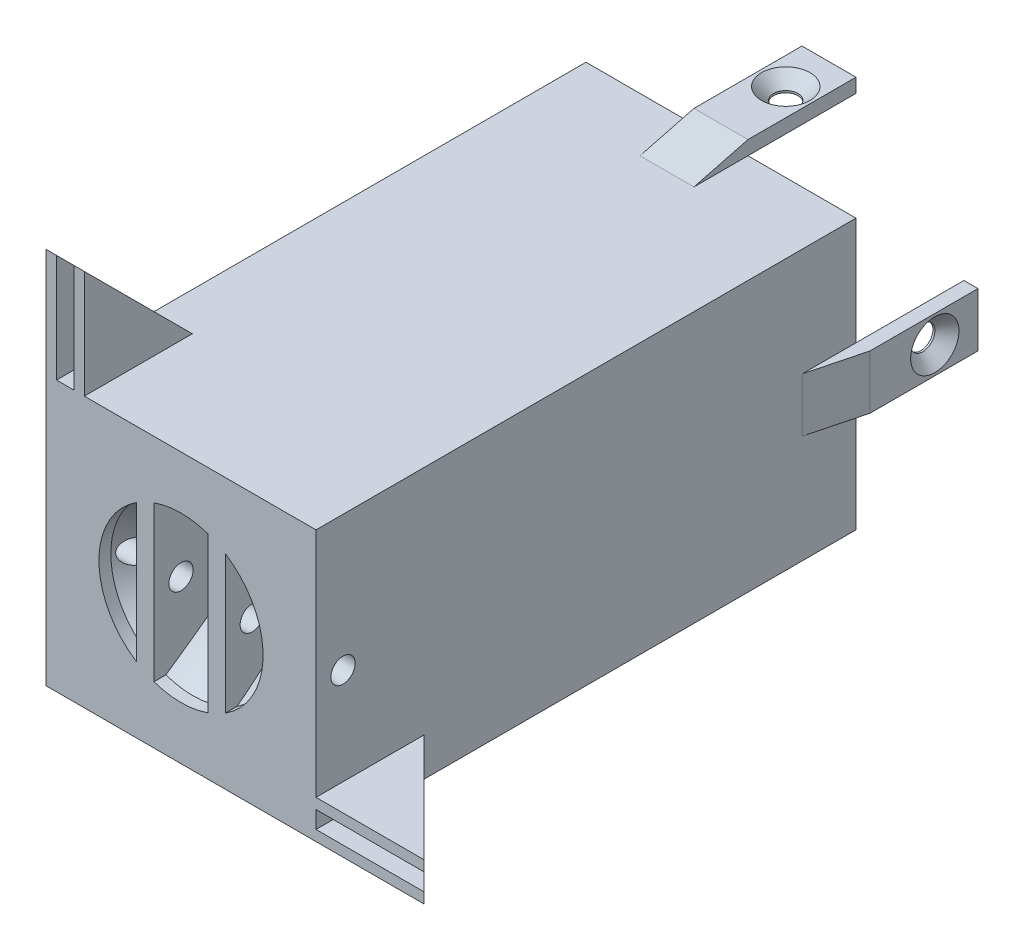
from build123d import *

# Parameters (mm, degrees)
CROQUIS1_W                                           = 50
CROQUIS1_H                                           = 50
CROQUIS1_R                                           = 2
SALIENTE_EXTRUIR2_DEPTH                              = 100
CROQUIS4_W                                           = 3.2
CROQUIS4_H                                           = 40
SALIENTE_EXTRUIR5_DEPTH                              = 10.2
CROQUIS8_R                                           = 4
CORTAR_EXTRUIR3_DEPTH                                = 87.4
CORTAR_EXTRUIR2_START                                = -50
CROQUIS7_R                                           = 2
CORTAR_EXTRUIR2_DEPTH                                = 50
REFRENTADO_PARA_TORNILLO_TAP_N_CON_CABEZ_D           = 4.5
REFRENTADO_PARA_TORNILLO_TAP_N_CON_CABEZ_CSINK_D     = 8.96
REFRENTADO_PARA_TORNILLO_TAP_N_CON_CABEZ_CSINK_ANGLE = 90
SALIENTE_EXTRUIR6_DEPTH                              = 1.95
SALIENTE_EXTRUIR7_START                              = -5.15
SALIENTE_EXTRUIR7_DEPTH                              = 1.95
SALIENTE_EXTRUIR9_DEPTH                              = 1.95
SALIENTE_EXTRUIR10_START                             = -5.15
SALIENTE_EXTRUIR10_DEPTH                             = 1.95
SALIENTE_EXTRUIR11_START                             = -25
SALIENTE_EXTRUIR11_DEPTH                             = 5
CROQUIS17_R                                          = 2.25
CORTAR_EXTRUIR4_DEPTH                                = 2.6
REFRENTADO_PARA_TORNILLO_TAP_N_CON_C_2_D             = 4.5
REFRENTADO_PARA_TORNILLO_TAP_N_CON_C_2_CSINK_D       = 8.96
REFRENTADO_PARA_TORNILLO_TAP_N_CON_C_2_CSINK_ANGLE   = 90


with BuildPart() as part:
    # Croquis1 → Saliente-Extruir2 (new body)
    with BuildSketch(Plane.XY):
        Rectangle(CROQUIS1_W, CROQUIS1_H)
        Circle(CROQUIS1_R, mode=Mode.SUBTRACT)
    extrude(amount=SALIENTE_EXTRUIR2_DEPTH)

    # Croquis2 → Cortar-Revolución1 (revolve, cut)
    with BuildSketch(Plane(origin=(0, 0, 0), x_dir=(0, 0, -1), z_dir=(1, 0, 0))):
        Polygon((-100, 15.2), (-100, 0), (-89.8, 0), (-89.8, 10), (-97.8, 15.2), align=None)
    revolve(axis=Axis((0, 0, 100), (0, 0, -1)), mode=Mode.SUBTRACT)

    # Croquis4 → Saliente-Extruir5 (add)
    with BuildSketch(Plane.XY.offset(100)):
        with Locations((-6.6, 0)):
            Rectangle(CROQUIS4_W, CROQUIS4_H)
        with Locations((6.6, 0)):
            Rectangle(CROQUIS4_W, CROQUIS4_H)
    extrude(amount=-SALIENTE_EXTRUIR5_DEPTH)

    # Croquis8 → Cortar-Extruir3 (cut)
    with BuildSketch(Plane.XY.offset(89.8)):
        Circle(CROQUIS8_R)
    extrude(amount=-CORTAR_EXTRUIR3_DEPTH, mode=Mode.SUBTRACT)

    # Croquis7 → Cortar-Extruir2 (cut)
    with BuildSketch(Plane.ZY.offset(25).offset(CORTAR_EXTRUIR2_START)):
        with Locations((95, 0)):
            Circle(CROQUIS7_R)
    extrude(amount=CORTAR_EXTRUIR2_DEPTH, mode=Mode.SUBTRACT)

    # Refrentado para tornillo tap_n con cabez (through all)
    with Locations(Plane.ZY.offset(25)):
        with Locations((95, 0)):
            CounterSinkHole(REFRENTADO_PARA_TORNILLO_TAP_N_CON_CABEZ_D / 2, REFRENTADO_PARA_TORNILLO_TAP_N_CON_CABEZ_CSINK_D / 2, counter_sink_angle=REFRENTADO_PARA_TORNILLO_TAP_N_CON_CABEZ_CSINK_ANGLE)

    # Croquis12 → Saliente-Extruir6 (add)
    with BuildSketch(Plane.ZY.offset(25)):
        Polygon((100, 45), (80, 25), (100, 25), align=None)
    extrude(amount=-SALIENTE_EXTRUIR6_DEPTH)

    # Croquis12_2 → Saliente-Extruir7 (add)
    with BuildSketch(Plane.ZY.offset(25).offset(SALIENTE_EXTRUIR7_START)):
        Polygon((100, 45), (80, 25), (100, 25), align=None)
    extrude(amount=-SALIENTE_EXTRUIR7_DEPTH)

    # Croquis15 → Saliente-Extruir9 (add)
    with BuildSketch(Plane.XZ.offset(25)):
        Polygon((25, 100), (25, 80), (45, 100), align=None)
    extrude(amount=-SALIENTE_EXTRUIR9_DEPTH)

    # Croquis15_2 → Saliente-Extruir10 (add)
    with BuildSketch(Plane.XZ.offset(25).offset(SALIENTE_EXTRUIR10_START)):
        Polygon((25, 100), (25, 80), (45, 100), align=None)
    extrude(amount=-SALIENTE_EXTRUIR10_DEPTH)

    # Croquis16 → Saliente-Extruir11 (add, symmetric)
    with BuildSketch(Plane(origin=(25, 0, 0), x_dir=(0, 0, -1), z_dir=(1, 0, 0)).offset(SALIENTE_EXTRUIR11_START)):
        Polygon((0, 25), (-10, 25), (0, 27.6), (20, 27.6), (20, 25), align=None)
    saliente_extruir11 = extrude(amount=SALIENTE_EXTRUIR11_DEPTH, both=True)

    # Croquis17 → Cortar-Extruir4 (cut)
    with BuildSketch(Plane(origin=(0, 27.6, 0), x_dir=(1, 0, 0), z_dir=(0, 1, 0))):
        with Locations((0, 12)):
            Circle(CROQUIS17_R)
    cortar_extruir4 = extrude(amount=-CORTAR_EXTRUIR4_DEPTH, mode=Mode.SUBTRACT)

    # Refrentado para tornillo tap_n con c 2 (through all)
    with Locations(Plane(origin=(0, 27.6, 0), x_dir=(1, 0, 0), z_dir=(0, 1, 0))):
        with Locations((0, 12)):
            refrentado_para_tornillo_tap_n_con_c_2 = CounterSinkHole(REFRENTADO_PARA_TORNILLO_TAP_N_CON_C_2_D / 2, REFRENTADO_PARA_TORNILLO_TAP_N_CON_C_2_CSINK_D / 2, counter_sink_angle=REFRENTADO_PARA_TORNILLO_TAP_N_CON_C_2_CSINK_ANGLE)

    # Simetría1: Saliente-Extruir11, Cortar-Extruir4, Refrentado para tornillo tap_n con c 2 across plane
    add(saliente_extruir11.mirror(Plane(origin=(0, 0, 0), x_dir=(0, 0, 1), z_dir=(0.707106781, -0.707106781, 0))))
    add(cortar_extruir4.mirror(Plane(origin=(0, 0, 0), x_dir=(0, 0, 1), z_dir=(0.707106781, -0.707106781, 0))), mode=Mode.SUBTRACT)
    add(refrentado_para_tornillo_tap_n_con_c_2.mirror(Plane(origin=(0, 0, 0), x_dir=(0, 0, 1), z_dir=(0.707106781, -0.707106781, 0))), mode=Mode.SUBTRACT)


solid = part.part
